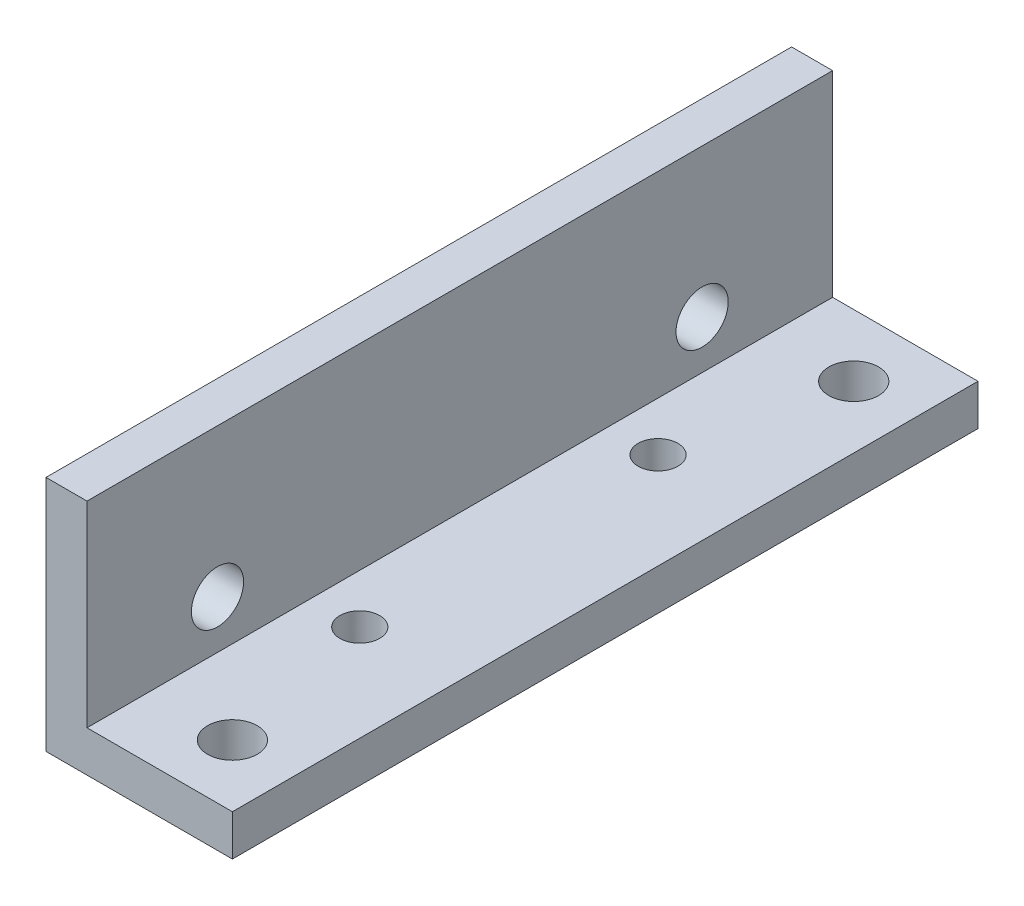
from build123d import *

# Parameters (mm, degrees)
EXTRUDE1_DEPTH               = 30
SKETCH2_W                    = 4.1
SKETCH2_H                    = 60
CUT_FOR_WALKER_CHASSIS_DEPTH = 20.1
F_4_2_4_2_DIAMETER_HOLE1_D   = 4.2
M4X0_7_TAPPED_HOLE1_D        = 4
M4X0_7_TAPPED_HOLE1_DEPTH    = 3.3
SKETCH7_R                    = 1.6
CUT_EXTRUDE1_DEPTH           = 20.1


with BuildPart() as part:
    # Sketch1 → Extrude1 (new body, symmetric)
    with BuildSketch(Plane.XY):
        Polygon((0, 0), (0, 19.1), (3.3, 19.1), (3.3, 3.3), (19.1, 3.3), (19.1, 0), align=None)
    extrude(amount=EXTRUDE1_DEPTH, both=True)

    # Sketch2 → Cut for walker chassis (cut, through all)
    with BuildSketch(Plane.XZ):
        with Locations((17.05, 0)):
            Rectangle(SKETCH2_W, SKETCH2_H)
    extrude(amount=-CUT_FOR_WALKER_CHASSIS_DEPTH, mode=Mode.SUBTRACT)

    # Ø4.2 (4.2) Diameter Hole1 (through all)
    with Locations(Plane.ZY):
        with Locations((-19.5, 7.18), (19.5, 7.18)):
            Hole(F_4_2_4_2_DIAMETER_HOLE1_D / 2)

    # M4x0.7 Tapped Hole1
    with Locations(Plane.XZ):
        with Locations((10, 25), (10, -25)):
            Hole(M4X0_7_TAPPED_HOLE1_D / 2, depth=M4X0_7_TAPPED_HOLE1_DEPTH)

    # Sketch7 → Cut-Extrude1 (cut, through all)
    with BuildSketch(Plane.XZ):
        with Locations((7.25, -12)):
            Circle(SKETCH7_R)
        with Locations((7.25, 12)):
            Circle(SKETCH7_R)
    extrude(amount=-CUT_EXTRUDE1_DEPTH, mode=Mode.SUBTRACT)


solid = part.part
